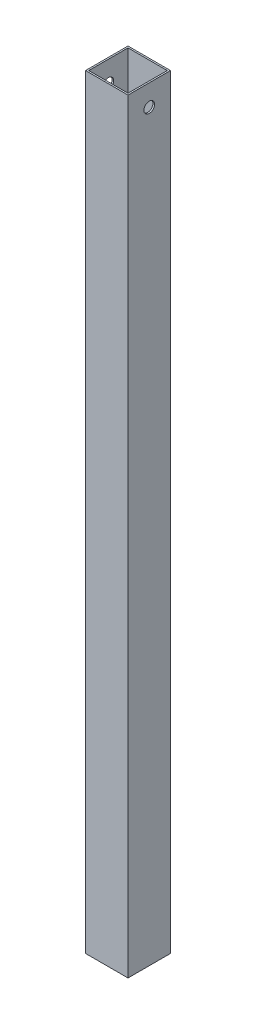
from build123d import *

# Parameters (mm, degrees)
SKETCH1_W           = 25.4
SKETCH1_H           = 25.4
SKETCH1_W_2         = 23.4696
SKETCH1_H_2         = 23.4696
BOSS_EXTRUDE1_DEPTH = 457.2
SKETCH2_R           = 3.175
CUT_EXTRUDE1_DEPTH  = 26.4


with BuildPart() as part:
    # Sketch1 → Boss-Extrude1 (new body)
    with BuildSketch(Plane(origin=(0, 0, 0), x_dir=(1, 0, 0), z_dir=(0, 1, 0))):
        Rectangle(SKETCH1_W, SKETCH1_H)
        Rectangle(SKETCH1_W_2, SKETCH1_H_2, mode=Mode.SUBTRACT)
    extrude(amount=BOSS_EXTRUDE1_DEPTH)

    # Sketch2 → Cut-Extrude1 (cut, through all)
    with BuildSketch(Plane(origin=(12.7, 0, 0), x_dir=(0, 0, -1), z_dir=(1, 0, 0))):
        with Locations((0, 444.5)):
            Circle(SKETCH2_R)
    extrude(amount=-CUT_EXTRUDE1_DEPTH, mode=Mode.SUBTRACT)


solid = part.part
